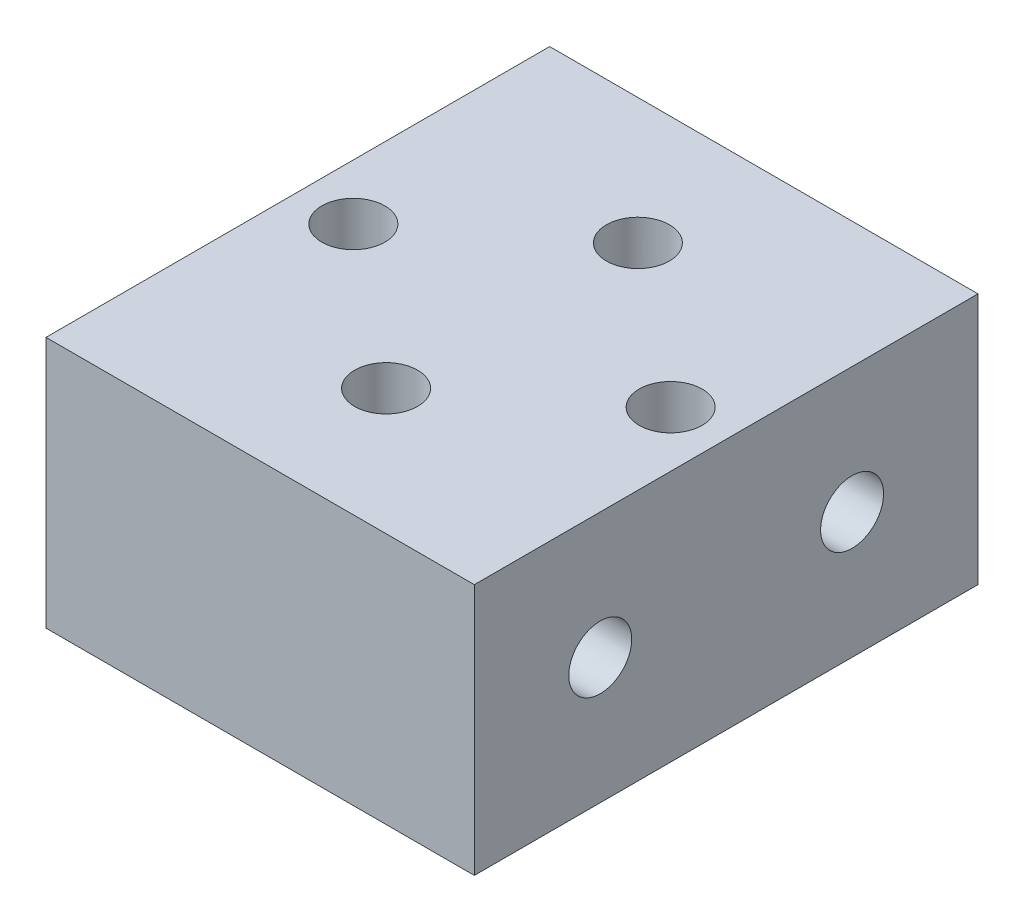
from build123d import *

# Parameters (mm, degrees)
SKETCH1_W                           = 8.1
SKETCH1_H                           = 9.525
BOSS_EXTRUDE1_DEPTH                 = 4.7625
F_0_80_TAPPED_HOLE1_D               = 1.19126
F_0_80_TAPPED_HOLE2_D               = 1.19126
F_3_64_0_04688_DIAMETER_HOLE1_D     = 1.190752
F_3_64_0_04688_DIAMETER_HOLE1_DEPTH = 12.954
F_3_64_0_04688_DIAMETER_HOLE1_TIP   = 0.357737992


with BuildPart() as part:
    # Sketch1 → Boss-Extrude1 (new body)
    with BuildSketch(Plane(origin=(0, 0, 0), x_dir=(1, 0, 0), z_dir=(0, 1, 0))):
        Rectangle(SKETCH1_W, SKETCH1_H)
    extrude(amount=BOSS_EXTRUDE1_DEPTH)

    # #0-80 Tapped Hole1 (through all)
    with Locations(Plane.ZY.offset(4.05)):
        with Locations((-2.38125, 2.38125), (2.38125, 2.38125)):
            Hole(F_0_80_TAPPED_HOLE1_D / 2)

    # #0-80 Tapped Hole2 (through all)
    with Locations(Plane.XZ):
        with Locations((-3, 0), (3, 0)):
            Hole(F_0_80_TAPPED_HOLE2_D / 2)

    # 3/64 (0.04688) Diameter Hole1
    with Locations(Plane(origin=(0, 4.7625, 0), x_dir=(-1, 0, 0), z_dir=(0, 1, 0))):
        with Locations((0, 2.38125), (0, -2.38125)):
            Hole(F_3_64_0_04688_DIAMETER_HOLE1_D / 2, depth=F_3_64_0_04688_DIAMETER_HOLE1_DEPTH)
            with Locations((0, 0, -(F_3_64_0_04688_DIAMETER_HOLE1_DEPTH + F_3_64_0_04688_DIAMETER_HOLE1_TIP / 2))):  # 118° drill point
                Cone(0, F_3_64_0_04688_DIAMETER_HOLE1_D / 2, F_3_64_0_04688_DIAMETER_HOLE1_TIP, mode=Mode.SUBTRACT)


solid = part.part
